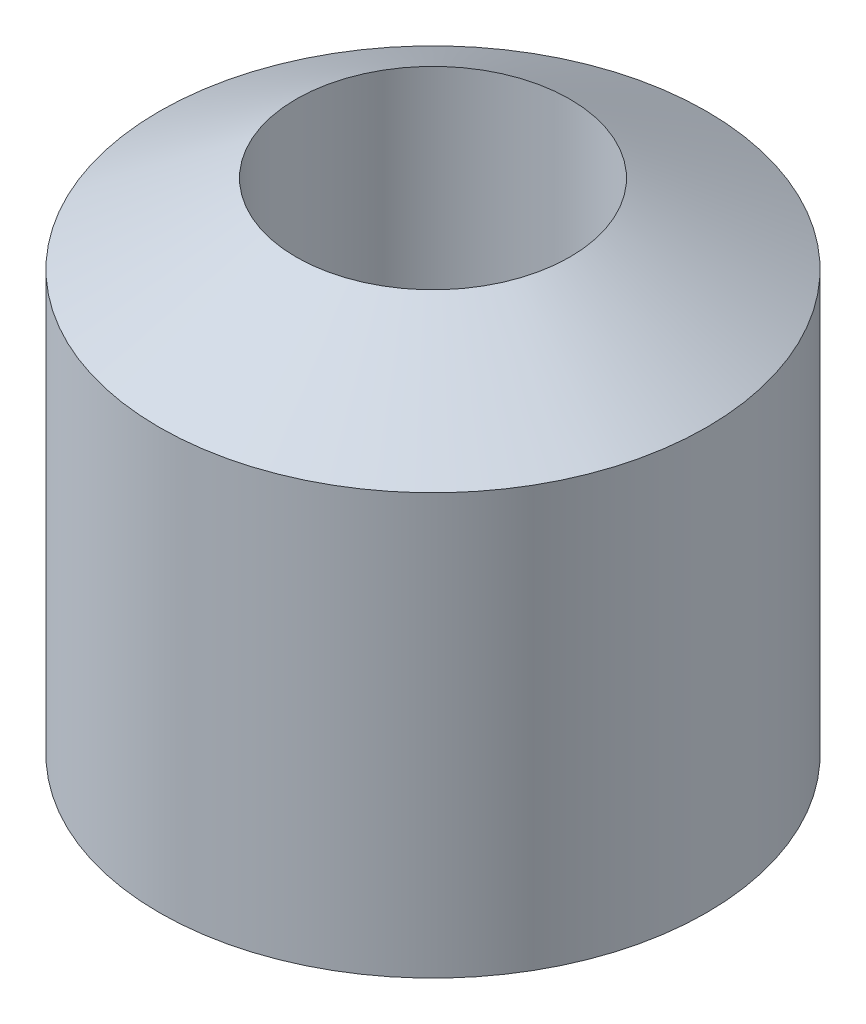
from build123d import *


with BuildPart() as part:
    # Sketch1 → Revolve1 (revolve)
    with BuildSketch(Plane.XY):
        Polygon((14, 29.582903769), (14, -29.582903769), (28, -21.5), (28, 21.5), align=None)
    revolve(axis=Axis((0, 91.25, 0), (0, -1, 0)))


solid = part.part
